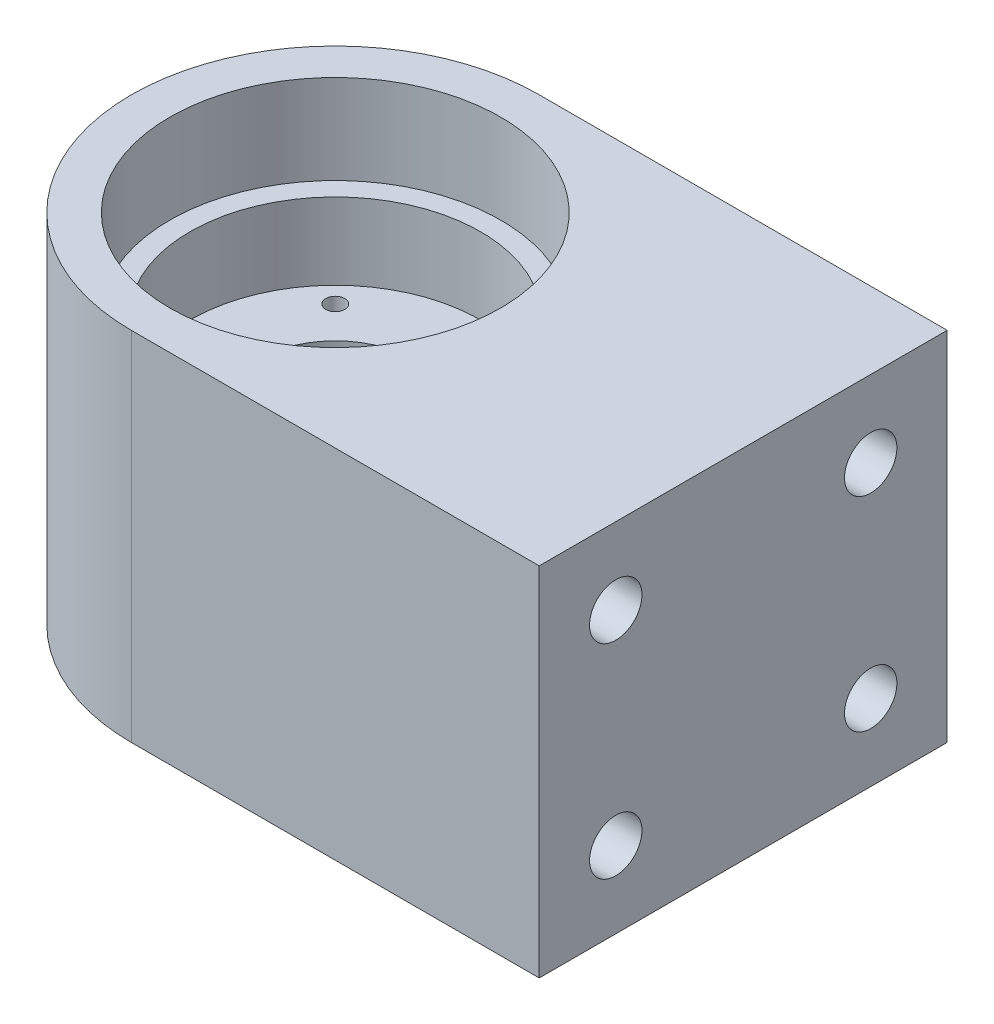
from build123d import *

# Parameters (mm, degrees)
SKETCH1_W           = 76.2
SKETCH1_H           = 50.8
BOSS_EXTRUDE1_DEPTH = 22.225
SKETCH2_R           = 20.5994
CUT_EXTRUDE1_DEPTH  = 11.1125
SKETCH3_R           = 18.0975
CUT_EXTRUDE2_DEPTH  = 9.525
SKETCH4_R           = 9.6266
CUT_EXTRUDE3_DEPTH  = 24.8125
SKETCH5_R           = 19.05
CUT_EXTRUDE4_DEPTH  = 17.4625
SKETCH6_R           = 11.303
CUT_EXTRUDE5_DEPTH  = 1.397
SKETCH7_R           = 3.2639
CUT_EXTRUDE6_DEPTH  = 19.05
SKETCH8_R           = 1.1811
CUT_EXTRUDE7_DEPTH  = 27.9875
CIRPATTERN1_COUNT   = 4
CUT_EXTRUDE8_DEPTH  = 45.45


with BuildPart() as part:
    # Sketch1 → Boss-Extrude1 (new body, symmetric)
    with BuildSketch(Plane(origin=(0, 0, 0), x_dir=(1, 0, 0), z_dir=(0, 1, 0))):
        with Locations((12.7, 0)):
            Rectangle(SKETCH1_W, SKETCH1_H)
    extrude(amount=BOSS_EXTRUDE1_DEPTH, both=True)

    # Sketch2 → Cut-Extrude1 (cut)
    with BuildSketch(Plane(origin=(0, 22.225, 0), x_dir=(1, 0, 0), z_dir=(0, 1, 0))):
        Circle(SKETCH2_R)
    extrude(amount=-CUT_EXTRUDE1_DEPTH, mode=Mode.SUBTRACT)

    # Sketch3 → Cut-Extrude2 (cut)
    with BuildSketch(Plane(origin=(0, 11.1125, 0), x_dir=(1, 0, 0), z_dir=(0, 1, 0))):
        Circle(SKETCH3_R)
    extrude(amount=-CUT_EXTRUDE2_DEPTH, mode=Mode.SUBTRACT)

    # Sketch4 → Cut-Extrude3 (cut, through all)
    with BuildSketch(Plane(origin=(0, 1.5875, 0), x_dir=(1, 0, 0), z_dir=(0, 1, 0))):
        Circle(SKETCH4_R)
    extrude(amount=-CUT_EXTRUDE3_DEPTH, mode=Mode.SUBTRACT)

    # Sketch5 → Cut-Extrude4 (cut)
    with BuildSketch(Plane.XZ.offset(22.225)):
        Circle(SKETCH5_R)
    extrude(amount=-CUT_EXTRUDE4_DEPTH, mode=Mode.SUBTRACT)

    # Sketch6 → Cut-Extrude5 (cut)
    with BuildSketch(Plane.XZ.offset(4.7625)):
        Circle(SKETCH6_R)
    extrude(amount=-CUT_EXTRUDE5_DEPTH, mode=Mode.SUBTRACT)

    # Sketch7 → Cut-Extrude6 (cut)
    with BuildSketch(Plane(origin=(50.8, 0, 0), x_dir=(0, 0, -1), z_dir=(1, 0, 0))):
        with Locations((-15.875, 12.7)):
            Circle(SKETCH7_R)
        with Locations((15.875, 12.7)):
            Circle(SKETCH7_R)
        with Locations((-15.875, -12.7)):
            Circle(SKETCH7_R)
        with Locations((15.875, -12.7)):
            Circle(SKETCH7_R)
    extrude(amount=-CUT_EXTRUDE6_DEPTH, mode=Mode.SUBTRACT)

    # Sketch8 → Cut-Extrude7 (cut, through all)
    with BuildSketch(Plane.XZ.offset(4.7625)):
        with Locations((-10.776307345, 10.776307345)):
            Circle(SKETCH8_R)
    cut_extrude7 = extrude(amount=-CUT_EXTRUDE7_DEPTH, mode=Mode.SUBTRACT)

    # CirPattern1: Cut-Extrude7 ×4 about axis
    cirpattern1_axis = Axis((0, 0, 0), (0, 1, 0))
    for i in range(1, CIRPATTERN1_COUNT):
        add(cut_extrude7.rotate(cirpattern1_axis, i * 360 / CIRPATTERN1_COUNT), mode=Mode.SUBTRACT)

    # Sketch9 → Cut-Extrude8 (cut, through all)
    with BuildSketch(Plane.XZ.offset(22.225)):
        with BuildLine():
            Line((0, 25.4), (0, 38.1))
            Line((0, 38.1), (-38.1, 38.1))
            Line((-38.1, 38.1), (-38.1, -38.1))
            Line((-38.1, -38.1), (0, -38.1))
            Line((0, -38.1), (0, -25.4))
            ThreePointArc((0, -25.4), (-25.4, 0), (0, 25.4))
        make_face()
    extrude(amount=-CUT_EXTRUDE8_DEPTH, mode=Mode.SUBTRACT)


solid = part.part
